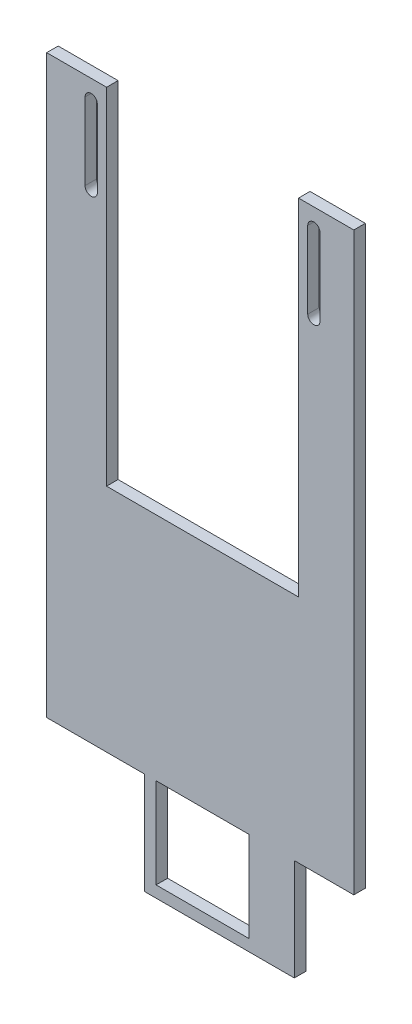
from build123d import *

# Parameters (mm, degrees)
SKETCH_1_W      = 24.2
SKETCH_1_H      = 23.5
EXTRUDE_1_DEPTH = 3


with BuildPart() as part:
    # 草图1 → 凸台-拉伸1 (new body)
    with BuildSketch(Plane.XY):
        Polygon((-30.949264706, 17.967420182), (-15.349264706, 17.967420182), (-15.349264706, -8.713823312), (-15.349264706, -72.032579818), (34.650735294, -72.032579818), (34.650735294, -8.713823312), (34.650735294, 17.967420182), (49.050735294, 17.967420182), (49.050735294, -132.032579818), (33.550735294, -132.032579818), (33.550735294, -158.532579818), (-5.449264706, -158.532579818), (-5.449264706, -132.032579818), (-30.949264706, -132.032579818), align=None)
        with BuildLine():
            Line((-17.749264706, 12.967420182), (-17.749264706, -7.032579818))
            ThreePointArc((-17.749264706, -7.032579818), (-19.349264706, -8.632579818), (-20.949264706, -7.032579818))
            Line((-20.949264706, -7.032579818), (-20.949264706, 12.967420182))
            ThreePointArc((-20.949264706, 12.967420182), (-19.349264706, 14.567420182), (-17.749264706, 12.967420182))
        make_face(mode=Mode.SUBTRACT)
        with BuildLine():
            Line((37.050735294, 12.967420182), (37.050735294, -7.032579818))
            ThreePointArc((37.050735294, -7.032579818), (38.650735294, -8.632579818), (40.250735294, -7.032579818))
            Line((40.250735294, -7.032579818), (40.250735294, 12.967420182))
            ThreePointArc((40.250735294, 12.967420182), (38.650735294, 14.567420182), (37.050735294, 12.967420182))
        make_face(mode=Mode.SUBTRACT)
        with Locations((9.650735294, -143.782579818)):
            Rectangle(SKETCH_1_W, SKETCH_1_H, mode=Mode.SUBTRACT)
    extrude(amount=EXTRUDE_1_DEPTH)


solid = part.part
